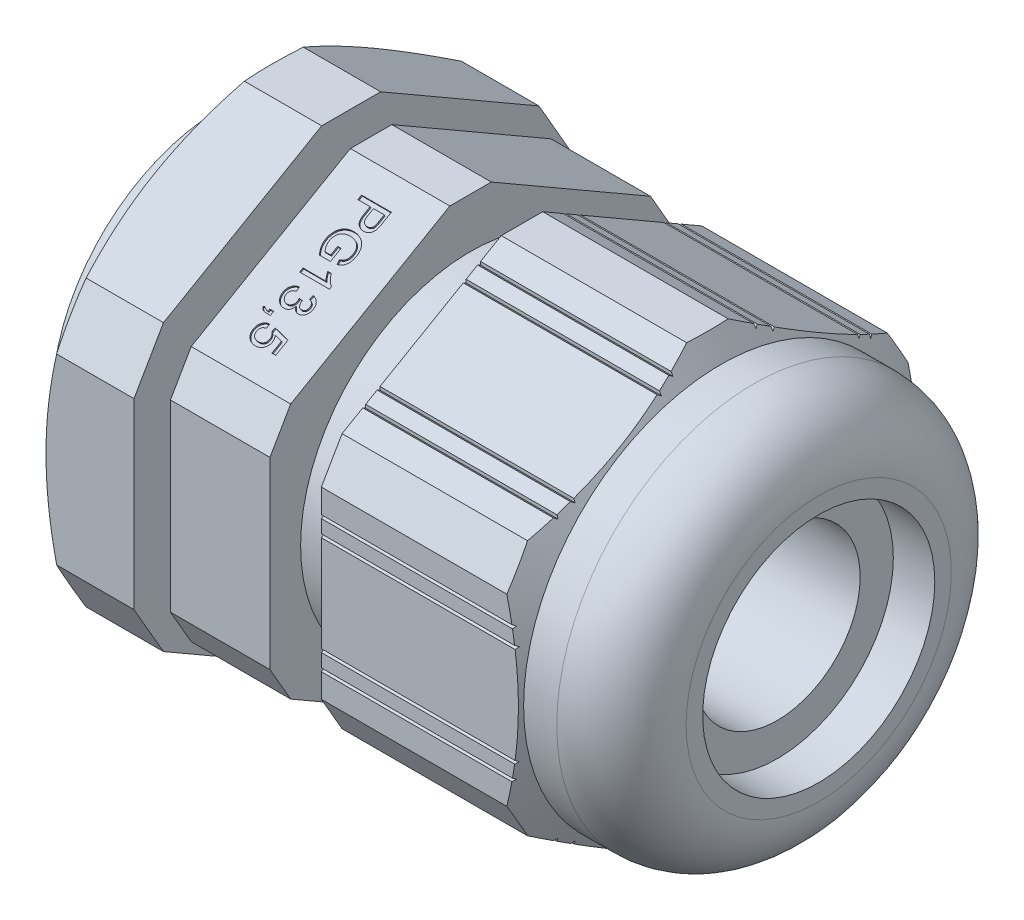
from build123d import *

# Parameters (mm, degrees)
ESBO_O1_R                = 7
RESSALTO_EXTRUS_O1_DEPTH = 18
ESBO_O2_W                = 3.1
ESBO_O2_H                = 3.721876514
ESBO_O2_W_2              = 9
ESBO_O3_OUTSIDE_W        = 36.52
ESBO_O3_OUTSIDE_H        = 40.264
CORTE_EXTRUS_O1_DEPTH    = 36
CORTE_EXTRUS_O3_START    = -11.770036
CORTE_EXTRUS_O3_DEPTH    = 11.770036
PADR_OCIRCULAR2_COUNT    = 6
ESBO_O6_R                = 10.25
PORCA_DEPTH              = 6
ESBO_O8_R                = 7
ESBO_O8_R_2              = 5
BORRACHA_DEPTH           = 10
PG13_5_DEPTH             = 0.1


with BuildPart() as part:
    # Esboço1 → Ressalto-extrusão1 (new body, symmetric)
    with BuildSketch(Plane(origin=(0, 0, 0), x_dir=(0, 0, -1), z_dir=(1, 0, 0))):
        Polygon((-12.1, 6.985938257), (-12.1, -6.985938257), (0, -13.971876514), (12.1, -6.985938257), (12.1, 6.985938257), (0, 13.971876514), align=None)
        Circle(ESBO_O1_R, mode=Mode.SUBTRACT)
    extrude(amount=RESSALTO_EXTRUS_O1_DEPTH, both=True)

    # Esboço2 → Corte-Revolução1 (revolve, cut)
    with BuildSketch(Plane.XY):
        with BuildLine():
            Line((14.1, 11.9), (12.1, 11.9))
            Line((12.1, 11.9), (10.903801537, 13.971876514))
            Line((10.903801537, 13.971876514), (18, 13.971876514))
            Line((18, 13.971876514), (18, 8))
            ThreePointArc((18, 8), (16.857716447, 10.757716447), (14.1, 11.9))
        make_face()
        with Locations((-1.45, 12.110938257)):
            Rectangle(ESBO_O2_W, ESBO_O2_H)
        with Locations((-13.5, 12.110938257)):
            Rectangle(ESBO_O2_W_2, ESBO_O2_H)
    revolve(axis=Axis((0, 0, 0), (1, 0, 0)), mode=Mode.SUBTRACT)

    # Esboço3 outside → Corte-extrusão1 (cut)
    with BuildSketch(Plane.ZY.offset(9)):
        Rectangle(ESBO_O3_OUTSIDE_W, ESBO_O3_OUTSIDE_H)
        Polygon((-7.649891067, 13.25), (-15.299782134, 0), (-7.649891067, -13.25), (7.649891067, -13.25), (15.299782134, 0), (7.649891067, 13.25), align=None, mode=Mode.SUBTRACT)
    extrude(amount=-CORTE_EXTRUS_O1_DEPTH, mode=Mode.SUBTRACT)

    # Esboço5 → Corte-extrusão3 (cut)
    with BuildSketch(Plane.ZY.offset(-0.1).offset(CORTE_EXTRUS_O3_START)):
        Polygon((12.1, 4.1), (11.926794919, 4), (12.1, 3.9), align=None)
        Polygon((12.1, 3.1), (11.926794919, 3), (12.1, 2.9), align=None)
        Polygon((12.1, -2.9), (12.1, -3.1), (11.926794919, -3), align=None)
        Polygon((12.1, -3.9), (12.1, -4.1), (11.926794919, -4), align=None)
    corte_extrus_o3 = extrude(amount=CORTE_EXTRUS_O3_DEPTH, mode=Mode.SUBTRACT)

    # PadrãoCircular2: Corte-extrusão3 ×6 about axis
    padr_ocircular2_axis = Axis((0, 0, 0), (1, 0, 0))
    for i in range(1, PADR_OCIRCULAR2_COUNT):
        add(corte_extrus_o3.rotate(padr_ocircular2_axis, i * 360 / PADR_OCIRCULAR2_COUNT), mode=Mode.SUBTRACT)

    # Esboço6 → PORCA (add)
    with BuildSketch(Plane.ZY.offset(10.2)):
        Polygon((-1.778083613, 14.1), (-11.321916387, 8.589865579), (-13.1, 5.510134421), (-13.1, -5.510134421), (-11.321916387, -8.589865579), (-1.778083613, -14.1), (1.778083613, -14.1), (11.321916387, -8.589865579), (13.1, -5.510134421), (13.1, 5.510134421), (11.321916387, 8.589865579), (1.778083613, 14.1), align=None)
        Circle(ESBO_O6_R, mode=Mode.SUBTRACT)
    extrude(amount=PORCA_DEPTH)

    # Esboço7 → Corte-Revolução2 (revolve, cut)
    with BuildSketch(Plane.XY):
        Polygon((-16.2, 11.9), (-13.313248654, 16.9), (-16.2, 16.9), align=None)
    revolve(axis=Axis((0, 0, 0), (-1, 0, 0)), mode=Mode.SUBTRACT)

    # Esboço9 → PG13,5 (cut)
    with BuildSketch(Plane(origin=(0, 10.478907386, 6.05), x_dir=(1, 0, 0), z_dir=(0, 0.866025404, 0.5))):
        with BuildLine():
            Line((-7, 4.010528408), (-5.202176921, 4.010528408))
            Line((-5.202176921, 4.010528408), (-5.202176921, 3.350030105))
            add(Edge.make_bspline(
                [(-5.202176921, 3.350030105), (-5.202328585, 3.322652741), (-5.202612747, 3.271357868), (-5.206088303, 3.199561358), (-5.210274609, 3.137901462), (-5.216340402, 3.100543487), (-5.21910354, 3.083525883)],
                knots=[0, 0, 0, 0, 8.2119e-05, 0.000153861, 0.000215651, 0.000267347, 0.000267347, 0.000267347, 0.000267347], degree=3))
            add(Edge.make_bspline(
                [(-5.21910354, 3.083525883), (-5.223100638, 3.062769853), (-5.230848128, 3.022538882), (-5.249484185, 2.965553516), (-5.272864619, 2.913633734), (-5.301442647, 2.866628983), (-5.335828867, 2.824545159), (-5.376380033, 2.787087745), (-5.42310648, 2.754077391), (-5.47515351, 2.725254509), (-5.531799333, 2.70244898), (-5.591701308, 2.685845721), (-5.654386188, 2.675367099), (-5.697208931, 2.674252329), (-5.718979028, 2.673685605)],
                knots=[0, 0, 0, 0, 6.3361e-05, 0.000122812, 0.000179383, 0.00023386, 0.000287352, 0.000341887, 0.000398949, 0.000458591, 0.000519984, 0.000581673, 0.000644788, 0.000710054, 0.000710054, 0.000710054, 0.000710054], degree=3))
            add(Edge.make_bspline(
                [(-5.718979028, 2.673685605), (-5.737606794, 2.674082599), (-5.774257943, 2.674863705), (-5.828103806, 2.681570879), (-5.879905585, 2.692149686), (-5.929309399, 2.707928894), (-5.976890601, 2.727221202), (-6.02185493, 2.751527227), (-6.064782103, 2.7799346), (-6.105740281, 2.812485998), (-6.143362044, 2.851187163), (-6.175503352, 2.897242689), (-6.202642925, 2.95007572), (-6.224394739, 3.010053886), (-6.24144025, 3.076905967), (-6.254035957, 3.150587848), (-6.261002679, 3.231288871), (-6.261942382, 3.287352403), (-6.262431557, 3.316537007)],
                knots=[0, 0, 0, 0, 5.5864e-05, 0.000109915, 0.000162536, 0.000214249, 0.000265278, 0.000316355, 0.000367296, 0.000419548, 0.000473036, 0.000528592, 0.000587384, 0.000650739, 0.000719571, 0.000794113, 0.000874747, 0.000962297, 0.000962297, 0.000962297, 0.000962297], degree=3))
            Line((-6.262431557, 3.316537007), (-6.262431557, 3.756989256))
            Line((-6.262431557, 3.756989256), (-7, 3.756989256))
            Line((-7, 3.756989256), (-7, 4.010528408))
        make_face()
        with BuildLine():
            Line((-6.054990433, 3.756989256), (-6.054990433, 3.323379683))
            add(Edge.make_bspline(
                [(-6.054990433, 3.323379683), (-6.054701269, 3.306085629), (-6.054144223, 3.272770238), (-6.050256854, 3.224631016), (-6.043527996, 3.180451089), (-6.03414321, 3.140107906), (-6.02247819, 3.103550097), (-6.00772515, 3.07084307), (-5.990028041, 3.042155487), (-5.969567197, 3.017297255), (-5.94664606, 2.995959269), (-5.921640364, 2.977470411), (-5.894371416, 2.961761278), (-5.864725125, 2.949447174), (-5.833278169, 2.93901543), (-5.799378964, 2.932504138), (-5.7635191, 2.927976858), (-5.738802099, 2.927478973), (-5.726181845, 2.927224758)],
                knots=[0, 0, 0, 0, 5.188e-05, 9.9943e-05, 0.000144765, 0.000185823, 0.000224089, 0.000259707, 0.000293187, 0.000324912, 0.000355997, 0.000386897, 0.000418032, 0.000450142, 0.000483057, 0.000517242, 0.000553514, 0.000591356, 0.000591356, 0.000591356, 0.000591356], degree=3))
            add(Edge.make_bspline(
                [(-5.726181845, 2.927224758), (-5.707880462, 2.927761822), (-5.672418773, 2.928802465), (-5.621390493, 2.939287205), (-5.574239459, 2.955725063), (-5.531858386, 2.979259237), (-5.494678897, 3.007742434), (-5.464259956, 3.041223828), (-5.439941133, 3.078629997), (-5.430312065, 3.106559221), (-5.425464242, 3.120620389)],
                knots=[0, 0, 0, 0, 5.4837e-05, 0.000106256, 0.000155579, 0.000204097, 0.000251066, 0.000295423, 0.000339286, 0.00038376, 0.00038376, 0.00038376, 0.00038376], degree=3))
            add(Edge.make_bspline(
                [(-5.425464242, 3.120620389), (-5.424205039, 3.12577004), (-5.421468704, 3.136960584), (-5.418362922, 3.155497632), (-5.415422022, 3.176981095), (-5.413470872, 3.201515693), (-5.411533132, 3.228877677), (-5.410639882, 3.259150696), (-5.409868369, 3.292403711), (-5.409704036, 3.315576016), (-5.409618045, 3.327701373)],
                knots=[0, 0, 0, 0, 1.5899e-05, 3.455e-05, 5.635e-05, 8.0935e-05, 0.000108365, 0.000138636, 0.000171776, 0.000208152, 0.000208152, 0.000208152, 0.000208152], degree=3))
            Line((-5.409618045, 3.327701373), (-5.409618045, 3.756989256))
            Line((-5.409618045, 3.756989256), (-6.054990433, 3.756989256))
        make_face(mode=Mode.SUBTRACT)
        with BuildLine():
            Line((-6.285480571, 1.521234913), (-6.078039446, 1.521234913))
            Line((-6.078039446, 1.521234913), (-6.078039446, 0.783666471))
            Line((-6.078039446, 0.783666471), (-6.74321958, 0.783666471))
            add(Edge.make_bspline(
                [(-6.74321958, 0.783666471), (-6.765382479, 0.812767761), (-6.809001813, 0.87004271), (-6.865906047, 0.959858501), (-6.914046123, 1.051081409), (-6.954050801, 1.14340193), (-6.984766237, 1.237483016), (-7.006676487, 1.332810629), (-7.020666194, 1.429344425), (-7.02225404, 1.494177533), (-7.023049014, 1.526637026)],
                knots=[0, 0, 0, 0, 0.000109702, 0.000215907, 0.000318527, 0.000418873, 0.000517387, 0.000614969, 0.000712046, 0.00080938, 0.00080938, 0.00080938, 0.00080938], degree=3))
            add(Edge.make_bspline(
                [(-7.023049014, 1.526637026), (-7.022715347, 1.548377855), (-7.022052507, 1.591566767), (-7.016379546, 1.655509714), (-7.007955904, 1.717961263), (-6.995549073, 1.778795143), (-6.979854916, 1.838144831), (-6.960207512, 1.895905291), (-6.937539776, 1.952255449), (-6.911465133, 2.006908077), (-6.881451617, 2.058960901), (-6.848916968, 2.108489835), (-6.812639809, 2.154385703), (-6.773436962, 2.196947619), (-6.730896782, 2.236022594), (-6.685615539, 2.272210591), (-6.636754811, 2.304533914), (-6.585217062, 2.333713713), (-6.53138606, 2.3594623), (-6.475742498, 2.382008729), (-6.418310742, 2.400415148), (-6.359696358, 2.416665899), (-6.299312224, 2.428242065), (-6.237556724, 2.437058935), (-6.17416019, 2.442073381), (-6.131348551, 2.44281899), (-6.10973184, 2.443195467)],
                knots=[0, 0, 0, 0, 6.521e-05, 0.000129543, 0.000192444, 0.000254174, 0.000315674, 0.00037649, 0.00043708, 0.000497807, 0.000557978, 0.00061721, 0.000675425, 0.000733277, 0.000790621, 0.000848554, 0.000906986, 0.000966174, 0.001026097, 0.001085884, 0.001146131, 0.001206935, 0.001268242, 0.001330429, 0.001394014, 0.001458865, 0.001458865, 0.001458865, 0.001458865], degree=3))
            add(Edge.make_bspline(
                [(-6.10973184, 2.443195467), (-6.088234551, 2.442821042), (-6.045541764, 2.442077448), (-5.981919614, 2.436975141), (-5.919425249, 2.428286942), (-5.85792872, 2.416504088), (-5.797753999, 2.40084767), (-5.738507704, 2.382235081), (-5.680524262, 2.359731388), (-5.623787, 2.334360971), (-5.56935317, 2.305908192), (-5.518216564, 2.273970784), (-5.470650973, 2.239202451), (-5.426927995, 2.201019815), (-5.386293073, 2.160461529), (-5.349951308, 2.11623445), (-5.31704043, 2.06929846), (-5.287867543, 2.019507083), (-5.26241059, 1.967138008), (-5.239989847, 1.912820281), (-5.22138498, 1.856429504), (-5.205688356, 1.798289195), (-5.19402553, 1.73807711), (-5.185252242, 1.67594847), (-5.180241201, 1.611833071), (-5.179502083, 1.568421687), (-5.179127907, 1.546444772)],
                knots=[0, 0, 0, 0, 6.449e-05, 0.000128075, 0.000191333, 0.0002537, 0.000315805, 0.000377766, 0.0004399, 0.000502283, 0.000564143, 0.000624002, 0.000682995, 0.000740692, 0.000797991, 0.000855031, 0.00091218, 0.000969808, 0.001027953, 0.00108674, 0.001145961, 0.001205976, 0.001267282, 0.001329826, 0.001394129, 0.00146006, 0.00146006, 0.00146006, 0.00146006], degree=3))
            add(Edge.make_bspline(
                [(-5.179127907, 1.546444772), (-5.179906377, 1.514841089), (-5.181433157, 1.452858144), (-5.192882236, 1.362196566), (-5.212959897, 1.276300421), (-5.239825537, 1.195481819), (-5.274440269, 1.121480913), (-5.314531192, 1.054581537), (-5.362264894, 0.99700945), (-5.415981075, 0.946979085), (-5.47750749, 0.904728262), (-5.546938525, 0.868501873), (-5.624576786, 0.836945796), (-5.680144683, 0.821295409), (-5.708895084, 0.81319802)],
                knots=[0, 0, 0, 0, 9.48e-05, 0.000185927, 0.000273548, 0.000359078, 0.000440927, 0.000518197, 0.000592391, 0.000664514, 0.000737743, 0.000815555, 0.000899084, 0.000988634, 0.000988634, 0.000988634, 0.000988634], degree=3))
            Line((-5.708895084, 0.81319802), (-5.7672379, 1.045128721))
            add(Edge.make_bspline(
                [(-5.7672379, 1.045128721), (-5.745895968, 1.051811355), (-5.705021411, 1.064610088), (-5.648041409, 1.087320828), (-5.598509545, 1.113103956), (-5.555234945, 1.141339157), (-5.517716955, 1.174807244), (-5.485014476, 1.214018857), (-5.45590302, 1.259214199), (-5.431467156, 1.310233153), (-5.411271274, 1.365789203), (-5.3970806, 1.424990659), (-5.388113499, 1.487107624), (-5.387091099, 1.529486617), (-5.386569031, 1.551126603)],
                knots=[0, 0, 0, 0, 6.708e-05, 0.000128473, 0.000183725, 0.000234367, 0.000283087, 0.000333949, 0.000387094, 0.000443951, 0.000503305, 0.000564099, 0.000626287, 0.000691176, 0.000691176, 0.000691176, 0.000691176], degree=3))
            add(Edge.make_bspline(
                [(-5.386569031, 1.551126603), (-5.387217723, 1.576721891), (-5.388473671, 1.626277507), (-5.397367894, 1.697988317), (-5.412764802, 1.764294859), (-5.434440954, 1.825083594), (-5.461335852, 1.880164641), (-5.491365875, 1.930417227), (-5.526136497, 1.974554742), (-5.564700128, 2.012933882), (-5.605976458, 2.046299266), (-5.648995222, 2.076055151), (-5.694110507, 2.101930969), (-5.725803323, 2.115751786), (-5.741667901, 2.122670118)],
                knots=[0, 0, 0, 0, 7.6778e-05, 0.000148652, 0.000216353, 0.0002806, 0.000341808, 0.00039999, 0.000455899, 0.000509887, 0.000562872, 0.000614918, 0.00066669, 0.000718582, 0.000718582, 0.000718582, 0.000718582], degree=3))
            add(Edge.make_bspline(
                [(-5.741667901, 2.122670118), (-5.769581391, 2.132953209), (-5.825792675, 2.153660964), (-5.914160807, 2.174709786), (-6.006136591, 2.187067279), (-6.068637181, 2.188784498), (-6.100368179, 2.189656315)],
                knots=[0, 0, 0, 0, 8.9179e-05, 0.000179586, 0.000271878, 0.000367053, 0.000367053, 0.000367053, 0.000367053], degree=3))
            add(Edge.make_bspline(
                [(-6.100368179, 2.189656315), (-6.119825284, 2.189532512), (-6.157942378, 2.18928998), (-6.213907162, 2.184926205), (-6.267600528, 2.179243948), (-6.318726931, 2.169933166), (-6.367586326, 2.159142281), (-6.413727577, 2.144741128), (-6.457874755, 2.128881389), (-6.499238407, 2.10959235), (-6.538242267, 2.088350161), (-6.574820284, 2.065054369), (-6.608363063, 2.038907979), (-6.639575156, 2.010647827), (-6.668352302, 1.980153364), (-6.694402707, 1.947270292), (-6.7175409, 1.911952784), (-6.745137424, 1.862444235), (-6.772896014, 1.7972446), (-6.797881496, 1.716477075), (-6.812565553, 1.632930718), (-6.814588106, 1.576392325), (-6.815607889, 1.547885336)],
                knots=[0, 0, 0, 0, 5.8353e-05, 0.000114315, 0.000168324, 0.000220251, 0.000270135, 0.000318325, 0.000365156, 0.000410759, 0.00045508, 0.000498336, 0.000540693, 0.000582507, 0.000624545, 0.000666335, 0.000708187, 0.000751073, 0.000836241, 0.000920203, 0.001004279, 0.001089781, 0.001089781, 0.001089781, 0.001089781], degree=3))
            add(Edge.make_bspline(
                [(-6.815607889, 1.547885336), (-6.814787509, 1.522876918), (-6.813150531, 1.472975345), (-6.801697534, 1.398578342), (-6.782451202, 1.325310777), (-6.756355961, 1.254583517), (-6.726253043, 1.188653145), (-6.694291287, 1.130186032), (-6.662285532, 1.079357154), (-6.637788144, 1.050762496), (-6.626173807, 1.037205623)],
                knots=[0, 0, 0, 0, 7.5014e-05, 0.000149682, 0.000225241, 0.000301918, 0.000375567, 0.000442451, 0.000501785, 0.000555277, 0.000555277, 0.000555277, 0.000555277], degree=3))
            Line((-6.626173807, 1.037205623), (-6.285480571, 1.037205623))
            Line((-6.285480571, 1.037205623), (-6.285480571, 1.521234913))
        make_face()
        with BuildLine():
            Line((-7, -0.29963718), (-7, -0.069147042))
            Line((-7, -0.069147042), (-5.599052128, -0.069147042))
            add(Edge.make_bspline(
                [(-5.599052128, -0.069147042), (-5.611849808, -0.055874638), (-5.638448385, -0.028289403), (-5.676115664, 0.018324916), (-5.714127151, 0.070341048), (-5.751175736, 0.126896092), (-5.7853698, 0.184989378), (-5.816571475, 0.240958989), (-5.842839838, 0.294023185), (-5.857216942, 0.328967297), (-5.864115787, 0.345735208)],
                knots=[0, 0, 0, 0, 5.529e-05, 0.000114913, 0.000179599, 0.000248522, 0.000317636, 0.00038179, 0.00044074, 0.000495122, 0.000495122, 0.000495122, 0.000495122], degree=3))
            Line((-5.864115787, 0.345735208), (-5.65163269, 0.345735208))
            add(Edge.make_bspline(
                [(-5.65163269, 0.345735208), (-5.636799682, 0.316933361), (-5.6075647, 0.260166627), (-5.557071868, 0.179967508), (-5.50233556, 0.105093002), (-5.443367893, 0.036782581), (-5.383092353, -0.02445336), (-5.322271965, -0.076057776), (-5.263136142, -0.119237067), (-5.221895464, -0.140900936), (-5.202176921, -0.151259153)],
                knots=[0, 0, 0, 0, 9.7153e-05, 0.000191483, 0.000283972, 0.000375145, 0.000461984, 0.000541438, 0.000614284, 0.000681026, 0.000681026, 0.000681026, 0.000681026], degree=3))
            Line((-5.202176921, -0.151259153), (-5.202176921, -0.29963718))
            Line((-5.202176921, -0.29963718), (-7, -0.29963718))
        make_face()
        with BuildLine():
            Line((-6.515970709, -0.875862526), (-6.492921696, -1.106352664))
            add(Edge.make_bspline(
                [(-6.492921696, -1.106352664), (-6.506769005, -1.10942951), (-6.533562521, -1.115382979), (-6.571978118, -1.126766659), (-6.60747635, -1.13902926), (-6.63987081, -1.153343722), (-6.669406549, -1.168582523), (-6.695898314, -1.185635059), (-6.719460896, -1.204026764), (-6.740175942, -1.223886338), (-6.758003338, -1.245505224), (-6.773624767, -1.268570259), (-6.786543525, -1.293511018), (-6.797116495, -1.320188172), (-6.805237625, -1.348564474), (-6.811463568, -1.37863523), (-6.815097732, -1.41046153), (-6.815435062, -1.432270763), (-6.815607889, -1.443444492)],
                knots=[0, 0, 0, 0, 4.2542e-05, 8.2316e-05, 0.000120133, 0.000155128, 0.000188473, 0.000219741, 0.000249496, 0.000278022, 0.000305643, 0.000333411, 0.00036144, 0.000389729, 0.000419361, 0.000449873, 0.00048177, 0.00051528, 0.00051528, 0.00051528, 0.00051528], degree=3))
            add(Edge.make_bspline(
                [(-6.815607889, -1.443444492), (-6.815421017, -1.456551401), (-6.815056054, -1.482149217), (-6.809580217, -1.519449456), (-6.802061371, -1.554947212), (-6.790271391, -1.588136025), (-6.775861856, -1.619478031), (-6.758054727, -1.648794674), (-6.737144701, -1.676286623), (-6.712989547, -1.70141162), (-6.686418107, -1.723880842), (-6.658351886, -1.743892842), (-6.628551401, -1.760440077), (-6.597436403, -1.774386904), (-6.564504086, -1.784681487), (-6.530165101, -1.792217952), (-6.494264153, -1.797143071), (-6.469769131, -1.797593299), (-6.457267752, -1.797823079)],
                knots=[0, 0, 0, 0, 3.9282e-05, 7.6717e-05, 0.00011289, 0.00014797, 0.000182128, 0.000216222, 0.000250652, 0.000285549, 0.000320549, 0.000354922, 0.000388782, 0.000422643, 0.00045704, 0.000492079, 0.000528039, 0.000565522, 0.000565522, 0.000565522, 0.000565522], degree=3))
            add(Edge.make_bspline(
                [(-6.457267752, -1.797823079), (-6.445362336, -1.797607457), (-6.4220545, -1.797185321), (-6.388020882, -1.792074607), (-6.355438921, -1.785255608), (-6.324644785, -1.774523422), (-6.295192005, -1.761272802), (-6.267608924, -1.744561018), (-6.241256961, -1.725365513), (-6.21711234, -1.703049243), (-6.19469424, -1.678858954), (-6.175656299, -1.652331853), (-6.159217564, -1.624429248), (-6.145946038, -1.594801718), (-6.135411789, -1.563576759), (-6.12784076, -1.530782922), (-6.123495406, -1.496262875), (-6.122966966, -1.472748236), (-6.122696911, -1.460731252)],
                knots=[0, 0, 0, 0, 3.5683e-05, 6.9858e-05, 0.000103062, 0.000135406, 0.000167477, 0.00019978, 0.000231977, 0.000265118, 0.000298259, 0.000330748, 0.000362867, 0.000395266, 0.000427951, 0.000461585, 0.000496071, 0.000532113, 0.000532113, 0.000532113, 0.000532113], degree=3))
            add(Edge.make_bspline(
                [(-6.122696911, -1.460731252), (-6.12298414, -1.450151992), (-6.12359694, -1.427581275), (-6.128745894, -1.39212491), (-6.136238051, -1.352893868), (-6.143406617, -1.325877988), (-6.147186488, -1.311632944)],
                knots=[0, 0, 0, 0, 3.1725e-05, 6.7685e-05, 0.000107309, 0.000151506, 0.000151506, 0.000151506, 0.000151506], degree=3))
            Line((-6.147186488, -1.311632944), (-5.939745363, -1.335402239))
            add(Edge.make_bspline(
                [(-5.939745363, -1.335402239), (-5.940426843, -1.341638747), (-5.941630784, -1.352656508), (-5.942074008, -1.363729831), (-5.942266349, -1.368535197)],
                knots=[0, 0, 0, 0, 1.8814e-05, 3.3237e-05, 3.3237e-05, 3.3237e-05, 3.3237e-05], degree=3))
            add(Edge.make_bspline(
                [(-5.942266349, -1.368535197), (-5.941431795, -1.389606141), (-5.93978544, -1.431173517), (-5.926845512, -1.491759445), (-5.905642554, -1.549117377), (-5.881458814, -1.59377575), (-5.857548196, -1.626317787), (-5.837084863, -1.647520689), (-5.814231746, -1.665625779), (-5.789150579, -1.680336814), (-5.761555491, -1.69152902), (-5.732010782, -1.699940039), (-5.700028595, -1.704459786), (-5.678055738, -1.705230678), (-5.666758606, -1.705627024)],
                knots=[0, 0, 0, 0, 6.3173e-05, 0.000124623, 0.0001849, 0.00024615, 0.000276258, 0.000305803, 0.000334263, 0.000363479, 0.000392706, 0.000423377, 0.000455414, 0.000489315, 0.000489315, 0.000489315, 0.000489315], degree=3))
            add(Edge.make_bspline(
                [(-5.666758606, -1.705627024), (-5.657622889, -1.705456533), (-5.639756003, -1.7051231), (-5.613559472, -1.701414624), (-5.588744283, -1.695268543), (-5.565013503, -1.687004932), (-5.542665654, -1.67604355), (-5.521223195, -1.663047494), (-5.500967446, -1.647555606), (-5.482439693, -1.629410008), (-5.465094129, -1.609917613), (-5.450336028, -1.588399559), (-5.437553681, -1.565709216), (-5.427616562, -1.5414361), (-5.419563789, -1.516033847), (-5.41390004, -1.4892582), (-5.410102048, -1.461080095), (-5.40978165, -1.441776822), (-5.409618045, -1.431919985)],
                knots=[0, 0, 0, 0, 2.7392e-05, 5.3571e-05, 7.9164e-05, 0.000103995, 0.000128801, 0.000153692, 0.00017912, 0.0002051, 0.00023139, 0.000257265, 0.00028322, 0.000309372, 0.000335798, 0.000363064, 0.000391385, 0.000420936, 0.000420936, 0.000420936, 0.000420936], degree=3))
            add(Edge.make_bspline(
                [(-5.409618045, -1.431919985), (-5.410370183, -1.412630276), (-5.411822672, -1.375378991), (-5.425261208, -1.322045738), (-5.447006509, -1.273716181), (-5.472507676, -1.237935308), (-5.496888235, -1.212527741), (-5.51755357, -1.195173028), (-5.540374126, -1.17965022), (-5.565341769, -1.165915323), (-5.59255691, -1.1541539), (-5.621682394, -1.143551303), (-5.65318452, -1.13534391), (-5.675012388, -1.131415999), (-5.686206211, -1.129401678)],
                knots=[0, 0, 0, 0, 5.7784e-05, 0.00011159, 0.000163809, 0.000215974, 0.000242463, 0.0002693, 0.00029677, 0.000325139, 0.000354649, 0.000385634, 0.000418042, 0.000452157, 0.000452157, 0.000452157, 0.000452157], degree=3))
            Line((-5.686206211, -1.129401678), (-5.663157197, -0.89891154))
            add(Edge.make_bspline(
                [(-5.663157197, -0.89891154), (-5.64533544, -0.902517085), (-5.610376661, -0.909589646), (-5.559886804, -0.923998909), (-5.512490656, -0.941570254), (-5.468408059, -0.962669641), (-5.427102332, -0.986291404), (-5.389096257, -1.013566983), (-5.353977185, -1.043795805), (-5.322378987, -1.077428653), (-5.293976402, -1.113274752), (-5.269111375, -1.151368448), (-5.24876945, -1.191860995), (-5.231618391, -1.234335316), (-5.218313785, -1.27894265), (-5.209090476, -1.325737968), (-5.203057146, -1.374499589), (-5.202473939, -1.407772048), (-5.202176921, -1.424717168)],
                knots=[0, 0, 0, 0, 5.4533e-05, 0.00010697, 0.000157341, 0.00020599, 0.000253431, 0.000299901, 0.000346113, 0.000392224, 0.00043812, 0.000483172, 0.000528431, 0.000573841, 0.000620444, 0.000667836, 0.000716795, 0.000767607, 0.000767607, 0.000767607, 0.000767607], degree=3))
            add(Edge.make_bspline(
                [(-5.202176921, -1.424717168), (-5.202934422, -1.44817549), (-5.204423914, -1.494302135), (-5.216368477, -1.562150788), (-5.235745186, -1.627100236), (-5.262732481, -1.688476679), (-5.295962647, -1.745035592), (-5.335409197, -1.795260724), (-5.380866113, -1.838310932), (-5.431673805, -1.8733275), (-5.485774464, -1.901053019), (-5.541931847, -1.921569738), (-5.600083077, -1.933828637), (-5.639451385, -1.935352769), (-5.659195648, -1.936117162)],
                knots=[0, 0, 0, 0, 7.0339e-05, 0.000138309, 0.000205989, 0.000273236, 0.000338954, 0.000402286, 0.000464194, 0.000526034, 0.000586757, 0.000646111, 0.000704946, 0.000764142, 0.000764142, 0.000764142, 0.000764142], degree=3))
            add(Edge.make_bspline(
                [(-5.659195648, -1.936117162), (-5.677859844, -1.935342223), (-5.714711405, -1.933812144), (-5.768594915, -1.922032335), (-5.819643482, -1.902126803), (-5.868036212, -1.875221998), (-5.912726573, -1.840333067), (-5.952549758, -1.797555839), (-5.987886815, -1.747574638), (-6.006279362, -1.710117955), (-6.015735081, -1.69086125)],
                knots=[0, 0, 0, 0, 5.5962e-05, 0.000110495, 0.000164535, 0.000219839, 0.000276031, 0.000333866, 0.000394615, 0.00045889, 0.00045889, 0.00045889, 0.00045889], degree=3))
            add(Edge.make_bspline(
                [(-6.015735081, -1.69086125), (-6.018994655, -1.703771615), (-6.025379208, -1.729059252), (-6.038608382, -1.765377541), (-6.054094316, -1.799522706), (-6.071641523, -1.831940281), (-6.092366008, -1.861721441), (-6.11518072, -1.88983869), (-6.140669492, -1.915595126), (-6.168491632, -1.939131369), (-6.198472777, -1.959962885), (-6.230184515, -1.978458875), (-6.263844096, -1.993961464), (-6.299384331, -2.006656301), (-6.336773125, -2.016286518), (-6.376046064, -2.02303995), (-6.416948221, -2.02753338), (-6.444890768, -2.028050724), (-6.459068456, -2.028313218)],
                knots=[0, 0, 0, 0, 3.9925e-05, 7.8202e-05, 0.000115757, 0.000152346, 0.000188608, 0.000224438, 0.000260855, 0.000297145, 0.000333612, 0.000370242, 0.000407142, 0.000444619, 0.000483316, 0.000522808, 0.000564091, 0.000606612, 0.000606612, 0.000606612, 0.000606612], degree=3))
            add(Edge.make_bspline(
                [(-6.459068456, -2.028313218), (-6.478423953, -2.027874373), (-6.516463714, -2.027011901), (-6.572346728, -2.018840975), (-6.625883449, -2.005475544), (-6.677287447, -1.98702277), (-6.726593212, -1.963510222), (-6.773614655, -1.934608427), (-6.817991189, -1.900013677), (-6.85999217, -1.861010486), (-6.898185256, -1.817880133), (-6.931614063, -1.771425994), (-6.959862829, -1.722189626), (-6.982924044, -1.670140631), (-7.001035756, -1.615384282), (-7.014020454, -1.55787496), (-7.021651299, -1.497432281), (-7.022576977, -1.456191426), (-7.023049014, -1.435161252)],
                knots=[0, 0, 0, 0, 5.8037e-05, 0.000114062, 0.000169003, 0.000223342, 0.000277628, 0.000332601, 0.000388572, 0.000446161, 0.000504332, 0.000561102, 0.000617565, 0.000674317, 0.000731602, 0.000790314, 0.000850931, 0.000914006, 0.000914006, 0.000914006, 0.000914006], degree=3))
            add(Edge.make_bspline(
                [(-7.023049014, -1.435161252), (-7.022692118, -1.416288885), (-7.021989513, -1.379135607), (-7.014718491, -1.324742723), (-7.004276571, -1.272550144), (-6.988567291, -1.22305144), (-6.968846415, -1.175864415), (-6.94408091, -1.131563193), (-6.9154952, -1.089321397), (-6.882433753, -1.049986302), (-6.845935896, -1.013787847), (-6.806549251, -0.981493892), (-6.764359187, -0.953763006), (-6.719997495, -0.929312754), (-6.672627787, -0.909550636), (-6.622656805, -0.894162697), (-6.570269993, -0.882429187), (-6.534267406, -0.878075229), (-6.515970709, -0.875862526)],
                knots=[0, 0, 0, 0, 5.6583e-05, 0.000111393, 0.000164367, 0.00021608, 0.000266916, 0.000317532, 0.000368076, 0.000419721, 0.000471417, 0.000522096, 0.000572238, 0.000622681, 0.000673849, 0.000725905, 0.000779382, 0.000834644, 0.000834644, 0.000834644, 0.000834644], degree=3))
        make_face()
        with BuildLine():
            Line((-7, -2.374048425), (-6.769509862, -2.374048425))
            Line((-6.769509862, -2.374048425), (-6.769509862, -2.604538564))
            Line((-6.769509862, -2.604538564), (-7, -2.604538564))
            add(Edge.make_bspline(
                [(-7, -2.604538564), (-7.022834866, -2.604010073), (-7.06638782, -2.603002083), (-7.128233026, -2.594824641), (-7.183275315, -2.581229288), (-7.232191481, -2.562367576), (-7.274684013, -2.536260456), (-7.311768619, -2.503888634), (-7.343845581, -2.46507401), (-7.360357283, -2.435327783), (-7.368784221, -2.420146453)],
                knots=[0, 0, 0, 0, 6.8487e-05, 0.000130626, 0.000186703, 0.000238265, 0.000287245, 0.000335489, 0.000385383, 0.000437388, 0.000437388, 0.000437388, 0.000437388], degree=3))
            Line((-7.368784221, -2.420146453), (-7.276588166, -2.374048425))
            add(Edge.make_bspline(
                [(-7.276588166, -2.374048425), (-7.270891231, -2.383160362), (-7.25955443, -2.401292955), (-7.237010844, -2.42451942), (-7.210901043, -2.444109437), (-7.180429319, -2.460045221), (-7.144513176, -2.471788089), (-7.102366054, -2.480552684), (-7.053461663, -2.486616498), (-7.018506587, -2.487895866), (-7, -2.488573213)],
                knots=[0, 0, 0, 0, 3.2164e-05, 6.4005e-05, 9.6418e-05, 0.000129763, 0.000166663, 0.000209399, 0.000258759, 0.000314296, 0.000314296, 0.000314296, 0.000314296], degree=3))
            Line((-7, -2.488573213), (-7, -2.374048425))
        make_face()
        with BuildLine():
            Line((-6.515970709, -2.950273771), (-6.492921696, -3.18076391))
            add(Edge.make_bspline(
                [(-6.492921696, -3.18076391), (-6.50590855, -3.183046124), (-6.531170001, -3.187485386), (-6.567736701, -3.195944889), (-6.601708188, -3.206931376), (-6.633378673, -3.219275904), (-6.662413282, -3.233949458), (-6.689270455, -3.249848375), (-6.712996846, -3.268597899), (-6.734833369, -3.288310506), (-6.754075207, -3.309946598), (-6.770296741, -3.333714947), (-6.784449046, -3.358952402), (-6.796036325, -3.385966344), (-6.804517603, -3.414798176), (-6.811224838, -3.445080945), (-6.814604582, -3.477204598), (-6.815269177, -3.499122346), (-6.815607889, -3.510292779)],
                knots=[0, 0, 0, 0, 3.9557e-05, 7.6944e-05, 0.000112479, 0.000146586, 0.000178798, 0.000209989, 0.000240028, 0.000269342, 0.000298173, 0.000326645, 0.000355503, 0.00038487, 0.000414605, 0.000445543, 0.000477797, 0.000511322, 0.000511322, 0.000511322, 0.000511322], degree=3))
            add(Edge.make_bspline(
                [(-6.815607889, -3.510292779), (-6.81527677, -3.523996399), (-6.814629252, -3.550794423), (-6.809152804, -3.589780472), (-6.800122777, -3.626605953), (-6.787485924, -3.661094661), (-6.771770502, -3.69365091), (-6.751421894, -3.723194666), (-6.728548047, -3.751336817), (-6.701278032, -3.77626641), (-6.671590065, -3.798959343), (-6.639184387, -3.818545051), (-6.604515836, -3.835033449), (-6.567591059, -3.848914879), (-6.528199118, -3.859165301), (-6.48654957, -3.866705315), (-6.442615885, -3.871545703), (-6.412503149, -3.872001529), (-6.397124232, -3.872234325)],
                knots=[0, 0, 0, 0, 4.1096e-05, 8.0364e-05, 0.000117836, 0.000154636, 0.000190391, 0.000225951, 0.00026201, 0.000298957, 0.000336484, 0.000373975, 0.000412313, 0.000451514, 0.000492135, 0.000534236, 0.000578422, 0.000624542, 0.000624542, 0.000624542, 0.000624542], degree=3))
            add(Edge.make_bspline(
                [(-6.397124232, -3.872234325), (-6.382468324, -3.871969733), (-6.353929874, -3.871454512), (-6.312373145, -3.867115506), (-6.273297243, -3.859795092), (-6.236271484, -3.850323162), (-6.201874442, -3.837267301), (-6.169607391, -3.821782315), (-6.140155135, -3.802812556), (-6.112600637, -3.781707448), (-6.087899139, -3.75760275), (-6.067041853, -3.730172811), (-6.048787516, -3.700493693), (-6.033984387, -3.667967626), (-6.022986219, -3.632575459), (-6.014524118, -3.594668892), (-6.010073399, -3.553854587), (-6.009293142, -3.525788057), (-6.008892405, -3.511373202)],
                knots=[0, 0, 0, 0, 4.3961e-05, 8.5602e-05, 0.000125158, 0.000163158, 0.000200082, 0.000235356, 0.000270325, 0.000304975, 0.000339355, 0.0003735, 0.000408089, 0.000443706, 0.000480381, 0.000519092, 0.000560056, 0.000603311, 0.000603311, 0.000603311, 0.000603311], degree=3))
            add(Edge.make_bspline(
                [(-6.008892405, -3.511373202), (-6.009430453, -3.493451883), (-6.010465862, -3.458964437), (-6.018766921, -3.409532039), (-6.032631789, -3.364625299), (-6.052902738, -3.324689413), (-6.077243361, -3.288931208), (-6.104770854, -3.256690897), (-6.135483736, -3.227707595), (-6.158606326, -3.211808929), (-6.170235502, -3.203812924)],
                knots=[0, 0, 0, 0, 5.3738e-05, 0.000103413, 0.000149884, 0.000194175, 0.000237227, 0.000279375, 0.000321167, 0.000363453, 0.000363453, 0.000363453, 0.000363453], degree=3))
            Line((-6.170235502, -3.203812924), (-6.147186488, -2.973322785))
            Line((-6.147186488, -2.973322785), (-5.225225934, -3.157714896))
            Line((-5.225225934, -3.157714896), (-5.225225934, -4.010528408))
            Line((-5.225225934, -4.010528408), (-5.455716073, -4.010528408))
            Line((-5.455716073, -4.010528408), (-5.455716073, -3.346068556))
            Line((-5.455716073, -3.346068556), (-5.921378181, -3.254592782))
            add(Edge.make_bspline(
                [(-5.921378181, -3.254592782), (-5.911835955, -3.267311183), (-5.893096533, -3.292288109), (-5.868536133, -3.331237795), (-5.847973478, -3.370683836), (-5.83076156, -3.410418785), (-5.817809214, -3.450993499), (-5.808547238, -3.491965917), (-5.802368686, -3.533395048), (-5.801757954, -3.56117078), (-5.80145128, -3.575118131)],
                knots=[0, 0, 0, 0, 4.7687e-05, 9.365e-05, 0.000137949, 0.000181029, 0.000223397, 0.000265507, 0.000306966, 0.000348781, 0.000348781, 0.000348781, 0.000348781], degree=3))
            add(Edge.make_bspline(
                [(-5.80145128, -3.575118131), (-5.801926878, -3.593270199), (-5.802863446, -3.629016025), (-5.810558548, -3.681688719), (-5.823621445, -3.732052741), (-5.841215432, -3.780502833), (-5.864538638, -3.826401262), (-5.892780419, -3.870208635), (-5.926162714, -3.911764605), (-5.964097476, -3.950770323), (-6.006027337, -3.986295202), (-6.051266653, -4.017430149), (-6.099498711, -4.043921012), (-6.150667839, -4.065508622), (-6.204865304, -4.082161302), (-6.261788274, -4.093862418), (-6.321659645, -4.101299222), (-6.362528271, -4.102242058), (-6.38343888, -4.102724463)],
                knots=[0, 0, 0, 0, 5.444e-05, 0.000107205, 0.000159265, 0.000210311, 0.000261528, 0.000313375, 0.000366413, 0.00042117, 0.000476367, 0.00053101, 0.000585649, 0.000641167, 0.000697327, 0.000755457, 0.000815316, 0.000878031, 0.000878031, 0.000878031, 0.000878031], degree=3))
            add(Edge.make_bspline(
                [(-6.38343888, -4.102724463), (-6.403384803, -4.102320137), (-6.442783692, -4.101521477), (-6.500825717, -4.094860671), (-6.556860568, -4.08417162), (-6.61062915, -4.068878264), (-6.662607045, -4.049899688), (-6.712153227, -4.025854343), (-6.760251377, -3.998363124), (-6.78988788, -3.976269954), (-6.804803664, -3.965150662)],
                knots=[0, 0, 0, 0, 5.9822e-05, 0.000118166, 0.000175024, 0.000230776, 0.0002857, 0.000340791, 0.000395826, 0.000451591, 0.000451591, 0.000451591, 0.000451591], degree=3))
            add(Edge.make_bspline(
                [(-6.804803664, -3.965150662), (-6.822216471, -3.9510282), (-6.856469332, -3.923247801), (-6.900927496, -3.875146343), (-6.938710816, -3.823436594), (-6.969407026, -3.767810823), (-6.994074029, -3.708642463), (-7.010488994, -3.645204648), (-7.021512293, -3.578263914), (-7.022529726, -3.532307801), (-7.023049014, -3.508852216)],
                knots=[0, 0, 0, 0, 6.7188e-05, 0.000132166, 0.000195846, 0.00025888, 0.000322349, 0.000387607, 0.000455047, 0.000525349, 0.000525349, 0.000525349, 0.000525349], degree=3))
            add(Edge.make_bspline(
                [(-7.023049014, -3.508852216), (-7.02265653, -3.489505099), (-7.021888752, -3.451658255), (-7.015215005, -3.396243414), (-7.004570507, -3.343538586), (-6.989310726, -3.293521523), (-6.970001586, -3.246062254), (-6.945619364, -3.201724231), (-6.917382078, -3.159918282), (-6.884938469, -3.121184239), (-6.849139011, -3.08542453), (-6.809639073, -3.054146187), (-6.767529446, -3.026639342), (-6.722934581, -3.002539454), (-6.67497636, -2.983778752), (-6.624617061, -2.968071621), (-6.571359563, -2.956424303), (-6.534627249, -2.952345445), (-6.515970709, -2.950273771)],
                knots=[0, 0, 0, 0, 5.8023e-05, 0.000113504, 0.000167184, 0.000219134, 0.000270163, 0.000320606, 0.00037065, 0.000421281, 0.000471958, 0.000522185, 0.000572129, 0.000622718, 0.000673945, 0.000726345, 0.000780878, 0.000837163, 0.000837163, 0.000837163, 0.000837163], degree=3))
        make_face()
    extrude(amount=-PG13_5_DEPTH, mode=Mode.SUBTRACT)


with BuildPart() as body_2:
    # Esboço8 → BORRACHA (new body)
    with BuildSketch(Plane(origin=(15.5, 0, 0), x_dir=(0, 0, -1), z_dir=(1, 0, 0))):
        Circle(ESBO_O8_R)
        Circle(ESBO_O8_R_2, mode=Mode.SUBTRACT)
    extrude(amount=-BORRACHA_DEPTH)


solid = Compound([part.part, body_2.part])
